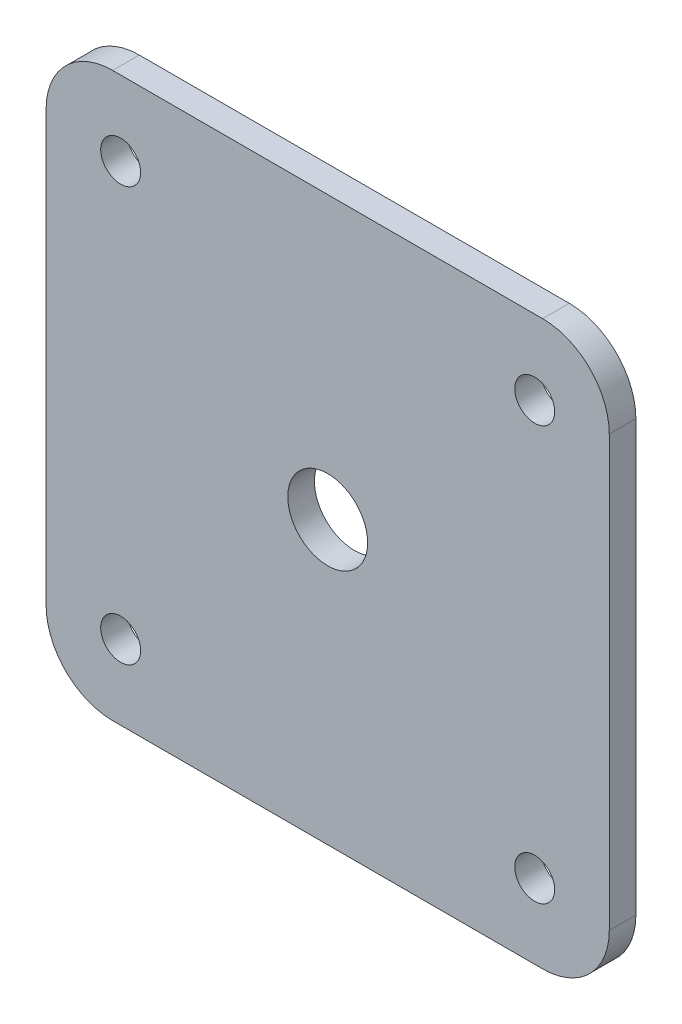
from build123d import *

# Parameters (mm, degrees)
SKETCH1_R           = 1.5
SKETCH1_R_2         = 3
BOSS_EXTRUDE1_DEPTH = 2


with BuildPart() as part:
    # Sketch1 → Boss-Extrude1 (new body)
    with BuildSketch(Plane.XY):
        with BuildLine():
            Line((-16.15, -21.15), (16.15, -21.15))
            ThreePointArc((16.15, -21.15), (19.685533906, -19.685533906), (21.15, -16.15))
            Line((21.15, -16.15), (21.15, 16.15))
            ThreePointArc((21.15, 16.15), (19.685533906, 19.685533906), (16.15, 21.15))
            Line((16.15, 21.15), (-16.15, 21.15))
            ThreePointArc((-16.15, 21.15), (-19.685533906, 19.685533906), (-21.15, 16.15))
            Line((-21.15, 16.15), (-21.15, -16.15))
            ThreePointArc((-21.15, -16.15), (-19.685533906, -19.685533906), (-16.15, -21.15))
        make_face()
        with Locations((-15.55, 15.55)):
            Circle(SKETCH1_R, mode=Mode.SUBTRACT)
        with Locations((15.55, 15.55)):
            Circle(SKETCH1_R, mode=Mode.SUBTRACT)
        with Locations((15.55, -15.55)):
            Circle(SKETCH1_R, mode=Mode.SUBTRACT)
        with Locations((-15.55, -15.55)):
            Circle(SKETCH1_R, mode=Mode.SUBTRACT)
        Circle(SKETCH1_R_2, mode=Mode.SUBTRACT)
    extrude(amount=BOSS_EXTRUDE1_DEPTH)


solid = part.part
